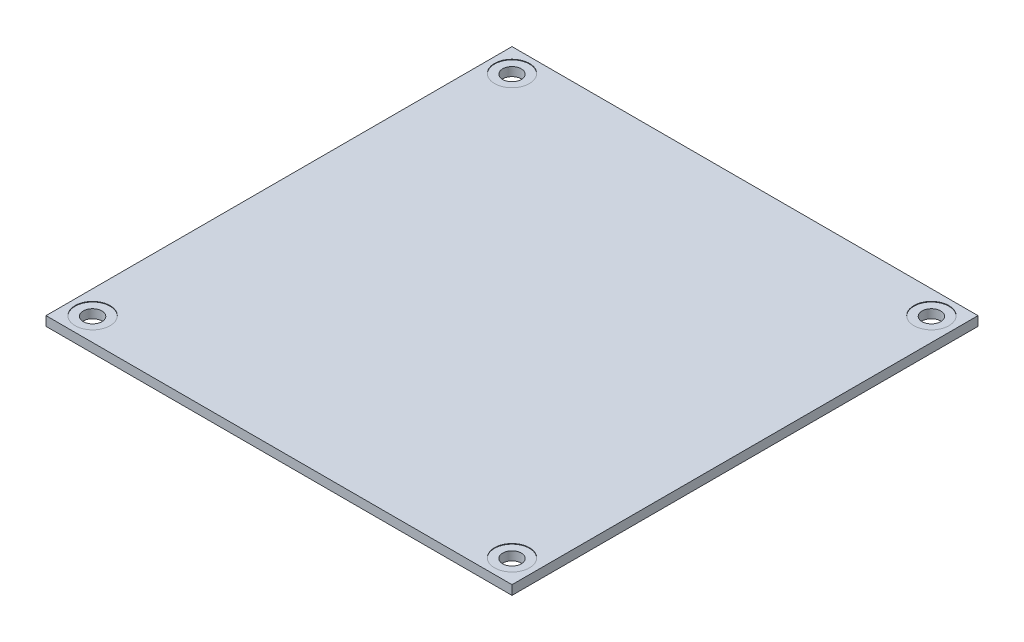
from build123d import *

# Parameters (mm, degrees)
SKETCH1_W           = 80
SKETCH1_H           = 80
BOSS_EXTRUDE1_DEPTH = 1.6
SKETCH5_R           = 3
CUT_EXTRUDE1_DEPTH  = 0.1
SKETCH6_R           = 1.6
CUT_EXTRUDE2_DEPTH  = 1.6


with BuildPart() as part:
    # Sketch1 → Boss-Extrude1 (new body)
    with BuildSketch(Plane(origin=(0, 0, 0), x_dir=(1, 0, 0), z_dir=(0, 1, 0))):
        Rectangle(SKETCH1_W, SKETCH1_H)
    extrude(amount=BOSS_EXTRUDE1_DEPTH)

    # Sketch5 → Cut-Extrude1 (cut)
    with BuildSketch(Plane(origin=(0, 1.6, 0), x_dir=(1, 0, 0), z_dir=(0, 1, 0))):
        with Locations((-36, 36)):
            Circle(SKETCH5_R)
        with Locations((36, 36)):
            Circle(SKETCH5_R)
        with Locations((36, -36)):
            Circle(SKETCH5_R)
        with Locations((-36, -36)):
            Circle(SKETCH5_R)
    extrude(amount=-CUT_EXTRUDE1_DEPTH, mode=Mode.SUBTRACT)

    # Sketch6 → Cut-Extrude2 (cut)
    with BuildSketch(Plane(origin=(0, 1.6, 0), x_dir=(1, 0, 0), z_dir=(0, 1, 0))):
        with Locations((-36, 36)):
            Circle(SKETCH6_R)
        with Locations((36, 36)):
            Circle(SKETCH6_R)
        with Locations((36, -36)):
            Circle(SKETCH6_R)
        with Locations((-36, -36)):
            Circle(SKETCH6_R)
    extrude(amount=-CUT_EXTRUDE2_DEPTH, mode=Mode.SUBTRACT)


solid = part.part
